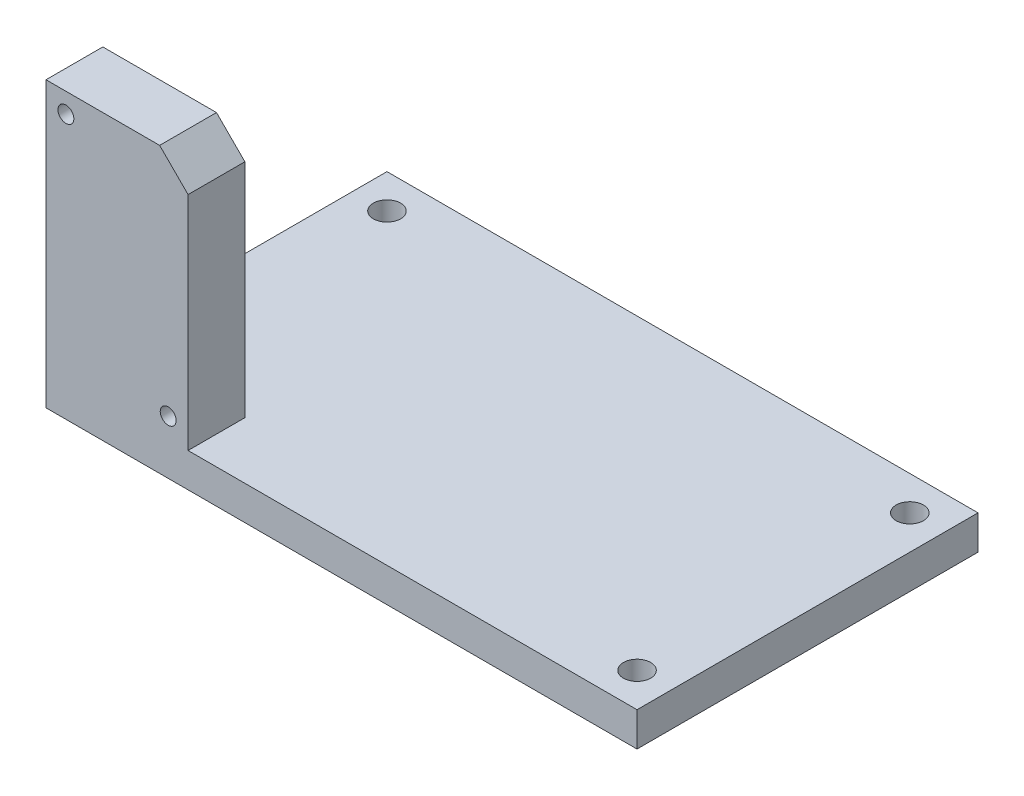
from build123d import *

# Parameters (mm, degrees)
SKETCH1_W           = 104
SKETCH1_H           = 60
SKETCH1_R           = 2.4
BOSS_EXTRUDE1_DEPTH = 6
SKETCH2_W           = 25
SKETCH2_H           = 44
BOSS_EXTRUDE2_DEPTH = 10
SKETCH3_R           = 1.4
CUT_EXTRUDE1_DEPTH  = 11
CHAMFER1_SIZE       = 5


with BuildPart() as part:
    # Sketch1 → Boss-Extrude1 (new body)
    with BuildSketch(Plane(origin=(0, 0, 0), x_dir=(1, 0, 0), z_dir=(0, 1, 0))):
        with Locations((46, 24)):
            Rectangle(SKETCH1_W, SKETCH1_H)
        with Locations((0, 48)):
            Circle(SKETCH1_R, mode=Mode.SUBTRACT)
        with Locations((92, 48)):
            Circle(SKETCH1_R, mode=Mode.SUBTRACT)
        with Locations((92, 0)):
            Circle(SKETCH1_R, mode=Mode.SUBTRACT)
        Circle(SKETCH1_R, mode=Mode.SUBTRACT)
    extrude(amount=BOSS_EXTRUDE1_DEPTH)

    # Sketch2 → Boss-Extrude2 (add)
    with BuildSketch(Plane.XY.offset(6)):
        with Locations((6.5, 28)):
            Rectangle(SKETCH2_W, SKETCH2_H)
    extrude(amount=-BOSS_EXTRUDE2_DEPTH)

    # Sketch3 → Cut-Extrude1 (cut, through all)
    with BuildSketch(Plane(origin=(0, 0, -4), x_dir=(-1, 0, 0), z_dir=(0, 0, -1))):
        with Locations((-15.5, 9.5)):
            Circle(SKETCH3_R)
        with Locations((2.5, 46.5)):
            Circle(SKETCH3_R)
    extrude(amount=-CUT_EXTRUDE1_DEPTH, mode=Mode.SUBTRACT)

    # Chamfer1
    chamfer1_edges = [part.edges().sort_by_distance(p)[0] for p in [
        (19, 50, 1),
    ]]
    chamfer(chamfer1_edges, length=CHAMFER1_SIZE)


solid = part.part
